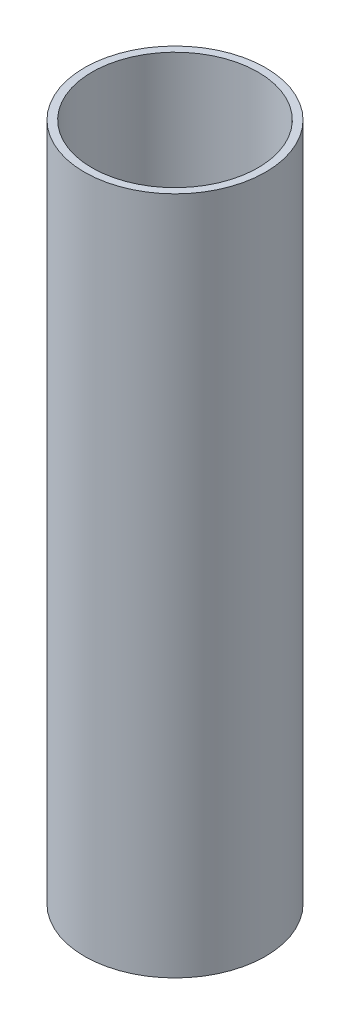
from build123d import *

# Parameters (mm, degrees)
SKETCH_1_R          = 24
EXTRUDE_1_DEPTH     = 180
SKETCH_2_R          = 22
CUT_EXTRUDE_1_DEPTH = 180


with BuildPart() as part:
    # 草圖1 → 填料-伸長1 (new body)
    with BuildSketch(Plane(origin=(0, 0, 0), x_dir=(1, 0, 0), z_dir=(0, 1, 0))):
        Circle(SKETCH_1_R)
    extrude(amount=EXTRUDE_1_DEPTH)

    # 草圖2 → 除料-伸長1 (cut)
    with BuildSketch(Plane(origin=(0, 180, 0), x_dir=(1, 0, 0), z_dir=(0, 1, 0))):
        Circle(SKETCH_2_R)
    extrude(amount=-CUT_EXTRUDE_1_DEPTH, mode=Mode.SUBTRACT)


solid = part.part
